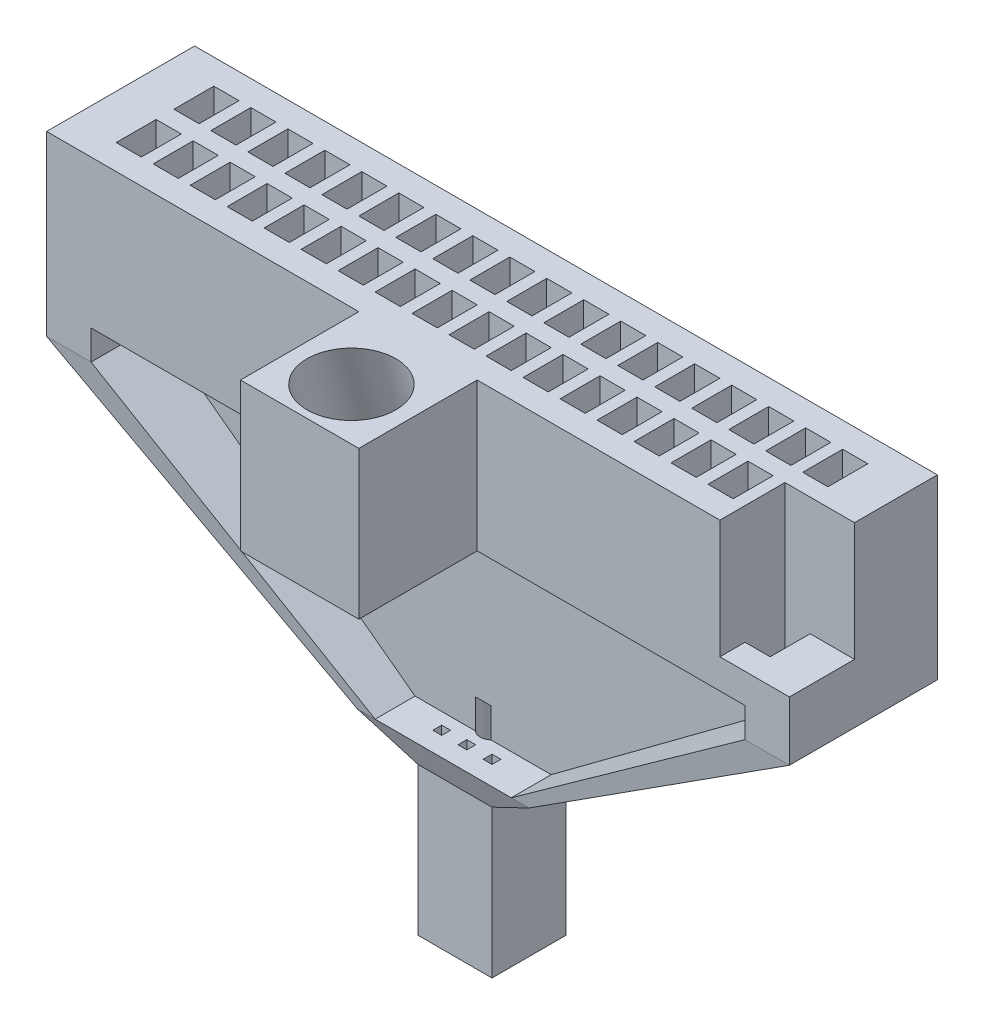
from build123d import *

# Parameters (mm, degrees)
MAIN_BLOCK_W             = 12.7508
MAIN_BLOCK_H             = 2.54
WELL_BLOCK_DEPTH         = 2.54
TOP_HOLES_W              = 0.4318
TOP_HOLES_H              = 0.6858
OMNETICS_WELLS_DEPTH     = 2.54
SKETCH8_W                = 0.762
SKETCH8_H                = 2.54
SUPPORTBEAM1_DEPTH       = 0.508
SKETCH10_W               = 0.762
SKETCH10_H               = 2.54
SUPPORTBEAM2_DEPTH       = 0.508
SKETCH7_W                = 0.3048
SKETCH7_H                = 1.77800034
SKETCH5_W                = 11.226700613
SKETCH5_H                = 0.3048
WALL_DIVIDER_DEPTH       = 0.508
SKETCH6_W                = 2.336782461
SKETCH6_H                = 0.3048
SKETCH12_W               = 2.9464
SKETCH12_H               = 1.77800034
SKETCH13_W               = 1.27
SKETCH13_H               = 1.27
SKETCH13_3_W             = 1.27
SKETCH13_3_H             = 1.27
TETRODE_FUNNEL_DEPTH     = 2.54
SKETCH17_W               = 1.1938
SKETCH17_H               = 1.1176
GROUND_WIRE_HOLE_DEPTH   = 2.032
SKETCH19_R               = 0.2032
FIBER_OPTIC_HOLE_DEPTH   = 3.556
SKETCH20_W               = 2.032
SKETCH20_H               = 2.54
FIBER_OPTIC_HOLDER_DEPTH = 2.032
SKETCH24_R               = 0.762
SKETCH25_R               = 0.762
TETRODE_SKETCH_W         = 0.1524
TETRODE_SKETCH_H         = 0.1524
CUT_EXTRUDE1_DEPTH       = 3.556


with BuildPart() as part:
    # main_block → well_block (new body)
    with BuildSketch(Plane(origin=(0, 0, 0), x_dir=(1, 0, 0), z_dir=(0, 1, 0))):
        with Locations((0.756592766, -0.05080017)):
            Rectangle(MAIN_BLOCK_W, MAIN_BLOCK_H)
    extrude(amount=-WELL_BLOCK_DEPTH)

    # top_holes → omnetics_wells (cut)
    with BuildSketch(Plane(origin=(0, 0, 0), x_dir=(1, 0, 0), z_dir=(0, 1, 0))):
        with Locations((6.154092766, 0.44449983)):
            Rectangle(TOP_HOLES_W, TOP_HOLES_H)
        with Locations((5.519098613, 0.44449983)):
            Rectangle(TOP_HOLES_W, TOP_HOLES_H)
        with Locations((4.884104459, 0.44449983)):
            Rectangle(TOP_HOLES_W, TOP_HOLES_H)
        with Locations((4.249110305, 0.44449983)):
            Rectangle(TOP_HOLES_W, TOP_HOLES_H)
        with Locations((3.614116151, 0.44449983)):
            Rectangle(TOP_HOLES_W, TOP_HOLES_H)
        with Locations((2.979121998, 0.44449983)):
            Rectangle(TOP_HOLES_W, TOP_HOLES_H)
        with Locations((2.344127844, 0.44449983)):
            Rectangle(TOP_HOLES_W, TOP_HOLES_H)
        with Locations((1.70913369, 0.44449983)):
            Rectangle(TOP_HOLES_W, TOP_HOLES_H)
        with Locations((1.074139537, 0.44449983)):
            Rectangle(TOP_HOLES_W, TOP_HOLES_H)
        with Locations((0.439145383, 0.44449983)):
            Rectangle(TOP_HOLES_W, TOP_HOLES_H)
        with Locations((-0.195848771, 0.44449983)):
            Rectangle(TOP_HOLES_W, TOP_HOLES_H)
        with Locations((-0.830842925, 0.44449983)):
            Rectangle(TOP_HOLES_W, TOP_HOLES_H)
        with Locations((-1.465837078, 0.44449983)):
            Rectangle(TOP_HOLES_W, TOP_HOLES_H)
        with Locations((-2.100831232, 0.44449983)):
            Rectangle(TOP_HOLES_W, TOP_HOLES_H)
        with Locations((-2.735825386, 0.44449983)):
            Rectangle(TOP_HOLES_W, TOP_HOLES_H)
        with Locations((-3.370819539, 0.44449983)):
            Rectangle(TOP_HOLES_W, TOP_HOLES_H)
        with Locations((-4.005813693, 0.44449983)):
            Rectangle(TOP_HOLES_W, TOP_HOLES_H)
        with Locations((-4.640807847, 0.44449983)):
            Rectangle(TOP_HOLES_W, TOP_HOLES_H)
        with Locations((5.519098613, -0.54610017)):
            Rectangle(TOP_HOLES_W, TOP_HOLES_H)
        with Locations((4.884104459, -0.54610017)):
            Rectangle(TOP_HOLES_W, TOP_HOLES_H)
        with Locations((4.249110305, -0.54610017)):
            Rectangle(TOP_HOLES_W, TOP_HOLES_H)
        with Locations((3.614116151, -0.54610017)):
            Rectangle(TOP_HOLES_W, TOP_HOLES_H)
        with Locations((2.979121998, -0.54610017)):
            Rectangle(TOP_HOLES_W, TOP_HOLES_H)
        with Locations((2.344127844, -0.54610017)):
            Rectangle(TOP_HOLES_W, TOP_HOLES_H)
        with Locations((1.70913369, -0.54610017)):
            Rectangle(TOP_HOLES_W, TOP_HOLES_H)
        with Locations((1.074139537, -0.54610017)):
            Rectangle(TOP_HOLES_W, TOP_HOLES_H)
        with Locations((0.439145383, -0.54610017)):
            Rectangle(TOP_HOLES_W, TOP_HOLES_H)
        with Locations((-0.195848771, -0.54610017)):
            Rectangle(TOP_HOLES_W, TOP_HOLES_H)
        with Locations((-0.830842925, -0.54610017)):
            Rectangle(TOP_HOLES_W, TOP_HOLES_H)
        with Locations((-1.465837078, -0.54610017)):
            Rectangle(TOP_HOLES_W, TOP_HOLES_H)
        with Locations((-2.100831232, -0.54610017)):
            Rectangle(TOP_HOLES_W, TOP_HOLES_H)
        with Locations((-2.735825386, -0.54610017)):
            Rectangle(TOP_HOLES_W, TOP_HOLES_H)
        with Locations((-3.370819539, -0.54610017)):
            Rectangle(TOP_HOLES_W, TOP_HOLES_H)
        with Locations((-4.005813693, -0.54610017)):
            Rectangle(TOP_HOLES_W, TOP_HOLES_H)
        with Locations((-4.640807847, -0.54610017)):
            Rectangle(TOP_HOLES_W, TOP_HOLES_H)
        with Locations((6.154092766, -0.54610017)):
            Rectangle(TOP_HOLES_W, TOP_HOLES_H)
    extrude(amount=-OMNETICS_WELLS_DEPTH, mode=Mode.SUBTRACT)

    # Sketch8 → supportbeam1 (add)
    with BuildSketch(Plane.XZ.offset(2.54)):
        with Locations((-5.237707847, 0.05080017)):
            Rectangle(SKETCH8_W, SKETCH8_H)
    extrude(amount=SUPPORTBEAM1_DEPTH)

    # Sketch10 → supportbeam2 (add)
    with BuildSketch(Plane.XZ.offset(2.54)):
        with Locations((6.750992766, 0.05080017)):
            Rectangle(SKETCH10_W, SKETCH10_H)
    extrude(amount=SUPPORTBEAM2_DEPTH)

    # Sketch9 → section 0 of arm1
    with BuildSketch(Plane(origin=(0, -6.35, 0), x_dir=(1, 0, 0), z_dir=(0, 1, 0)), mode=Mode.PRIVATE) as arm1_s0:
        Polygon((1.92503369, -0.88900017), (1.924934303, 0.88900017), (2.229734303, 0.889017208), (2.22983369, -0.888983133), align=None)
    # loft up to a face of the part (arm1)
    loft([arm1_s0.sketch, part.faces().sort_by_distance((6.750992766, -3.048, 0.05080017))[0]])

    # Sketch7 → section 0 of arm2
    with BuildSketch(Plane(origin=(0, -6.35, 0), x_dir=(1, 0, 0), z_dir=(0, 1, 0)), mode=Mode.PRIVATE) as arm2_s0:
        with Locations((-0.564148771, 0)):
            Rectangle(SKETCH7_W, SKETCH7_H)
    # loft up to a face of the part (arm2)
    loft([arm2_s0.sketch, part.faces().sort_by_distance((-5.237707847, -3.048, 0.05080017))[0]])

    # Sketch5 → wall_divider (add)
    with BuildSketch(Plane.XZ.offset(2.54)):
        with Locations((0.75664246, 0.05080017)):
            Rectangle(SKETCH5_W, SKETCH5_H)
    extrude(amount=WALL_DIVIDER_DEPTH)

    # Sketch6 → section 1 of wall_divider2
    with BuildSketch(Plane(origin=(0, -6.35, 0), x_dir=(1, 0, 0), z_dir=(0, 1, 0)), mode=Mode.PRIVATE) as wall_divider2_s1:
        with Locations((0.756642459, -0.05080017)):
            Rectangle(SKETCH6_W, SKETCH6_H)
    # loft from a face of the part (wall_divider2)
    loft([part.faces().sort_by_distance((0.75664246, -3.048, 0.05080017))[0], wall_divider2_s1.sketch])

    # Sketch12 → exit_base section 0
    with BuildSketch(Plane(origin=(0, -6.35, 0), x_dir=(1, 0, 0), z_dir=(0, 1, 0))):
        with Locations((0.756651229, 0)):
            Rectangle(SKETCH12_W, SKETCH12_H)
    # Sketch13 → exit_base section 1
    with BuildSketch(Plane(origin=(0, -6.858, 0), x_dir=(1, 0, 0), z_dir=(0, 1, 0))):
        with Locations((0.756639537, -0.050800172)):
            Rectangle(SKETCH13_W, SKETCH13_H)
    loft()

    # Sketch13_3 → tetrode_funnel (add)
    with BuildSketch(Plane(origin=(0, -6.858, 0), x_dir=(1, 0, 0), z_dir=(0, 1, 0))):
        with Locations((0.756639537, -0.050800172)):
            Rectangle(SKETCH13_3_W, SKETCH13_3_H)
    extrude(amount=-TETRODE_FUNNEL_DEPTH)

    # Sketch17 → ground_wire_hole (cut)
    with BuildSketch(Plane(origin=(0, 0, 0), x_dir=(1, 0, 0), z_dir=(0, 1, 0))):
        with Locations((6.535092766, -0.76200017)):
            Rectangle(SKETCH17_W, SKETCH17_H)
    extrude(amount=-GROUND_WIRE_HOLE_DEPTH, mode=Mode.SUBTRACT)

    # Sketch19 → fiber_optic_hole (cut)
    with BuildSketch(Plane.XZ.offset(9.398)):
        with Locations((0.756639537, 0.050800172)):
            Circle(SKETCH19_R)
    extrude(amount=-FIBER_OPTIC_HOLE_DEPTH, mode=Mode.SUBTRACT)

    # Sketch20 → fiber_optic_holder (add)
    with BuildSketch(Plane.XY.offset(1.32080017)):
        with Locations((0.756592766, -1.27)):
            Rectangle(SKETCH20_W, SKETCH20_H)
    extrude(amount=FIBER_OPTIC_HOLDER_DEPTH)

    # Sketch24 → Cut-Loft1 section 0
    with BuildSketch(Plane.XZ.offset(2.54)):
        with Locations((0.760600593, 1.77800017)):
            Circle(SKETCH24_R)
    # Sketch25 → Cut-Loft1 section 1
    with BuildSketch(Plane(origin=(0, 0, 0), x_dir=(1, 0, 0), z_dir=(0, 1, 0))):
        with Locations((0.756592766, -2.46380017)):
            Circle(SKETCH25_R)
    loft(mode=Mode.SUBTRACT)

    # tetrode_sketch → Cut-Extrude1 (cut)
    with BuildSketch(Plane.XZ.offset(9.398)):
        with Locations((0.756639537, 0.482600172)):
            Rectangle(TETRODE_SKETCH_W, TETRODE_SKETCH_H)
        with Locations((1.188439537, 0.482600172)):
            Rectangle(TETRODE_SKETCH_W, TETRODE_SKETCH_H)
        with Locations((0.324839537, 0.482600172)):
            Rectangle(TETRODE_SKETCH_W, TETRODE_SKETCH_H)
        with Locations((0.324839537, 0.050800172)):
            Rectangle(TETRODE_SKETCH_W, TETRODE_SKETCH_H)
        with Locations((0.756639537, -0.380999828)):
            Rectangle(TETRODE_SKETCH_W, TETRODE_SKETCH_H)
        with Locations((0.324839537, -0.380999828)):
            Rectangle(TETRODE_SKETCH_W, TETRODE_SKETCH_H)
        with Locations((1.188439537, 0.050800172)):
            Rectangle(TETRODE_SKETCH_W, TETRODE_SKETCH_H)
        with Locations((1.188439537, -0.380999828)):
            Rectangle(TETRODE_SKETCH_W, TETRODE_SKETCH_H)
    extrude(amount=-CUT_EXTRUDE1_DEPTH, mode=Mode.SUBTRACT)


solid = part.part
